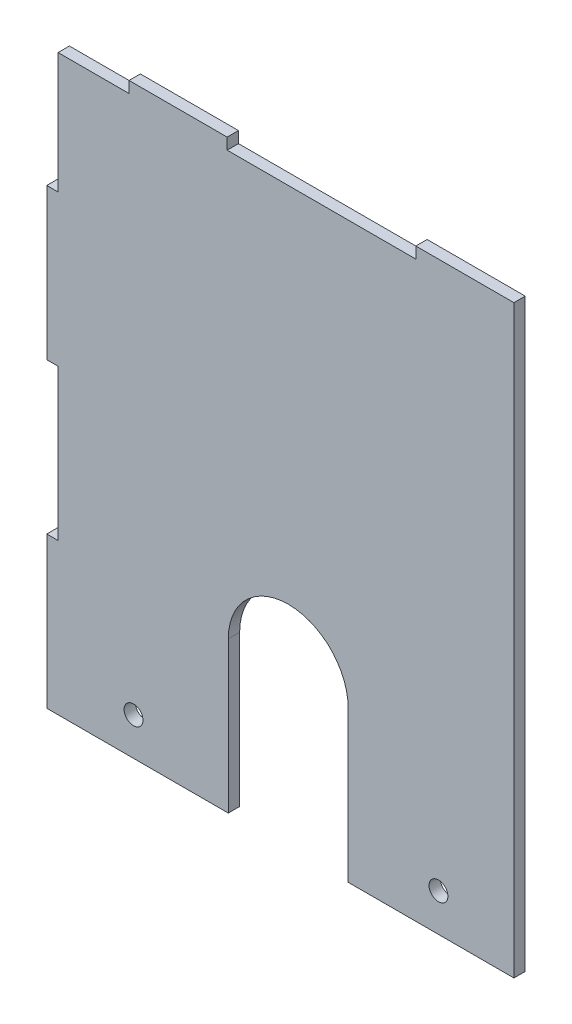
from build123d import *

# Parameters (mm, degrees)
SKETCH1_R           = 2.5
BOSS_EXTRUDE1_DEPTH = 3


with BuildPart() as part:
    # Sketch1 → Boss-Extrude1 (new body)
    with BuildSketch(Plane.XY):
        with BuildLine():
            Line((34.37, 75.95596391), (-15.63, 75.95596391))
            Line((-15.63, 75.95596391), (-15.63, 78.95596391))
            Line((-15.63, 78.95596391), (-41.63, 78.95596391))
            Line((-41.63, 78.95596391), (-41.63, 75.95596391))
            Line((-41.63, 75.95596391), (-60.44, 75.95596391))
            Line((-60.44, 75.95596391), (-60.44, 43.95596391))
            Line((-60.44, 43.95596391), (-63.44, 43.95596391))
            Line((-63.44, 43.95596391), (-63.44, 3.95596391))
            Line((-63.44, 3.95596391), (-60.44, 3.95596391))
            Line((-60.44, 3.95596391), (-60.44, -36.04403609))
            Line((-60.44, -36.04403609), (-63.44, -36.04403609))
            Line((-63.44, -36.04403609), (-63.44, -76.04403609))
            Line((-63.44, -76.04403609), (-60.44, -76.04403609))
            Line((-60.44, -76.04403609), (-15.324347337, -76.04403609))
            Line((-15.324347337, -76.04403609), (-15.324347337, -36.04403609))
            ThreePointArc((-15.324347337, -36.04403609), (0.56, -20.159688753), (16.444347337, -36.04403609))
            Line((16.444347337, -36.04403609), (16.444347337, -76.04403609))
            Line((16.444347337, -76.04403609), (60.37, -76.04403609))
            Line((60.37, -76.04403609), (60.37, 75.95596391))
            Line((60.37, 75.95596391), (60.37, 78.95596391))
            Line((60.37, 78.95596391), (34.37, 78.95596391))
            Line((34.37, 78.95596391), (34.37, 75.95596391))
        make_face()
        with Locations((-40.44, -66.04403609)):
            Circle(SKETCH1_R, mode=Mode.SUBTRACT)
        with Locations((40.37, -66.04403609)):
            Circle(SKETCH1_R, mode=Mode.SUBTRACT)
    extrude(amount=BOSS_EXTRUDE1_DEPTH)


solid = part.part
